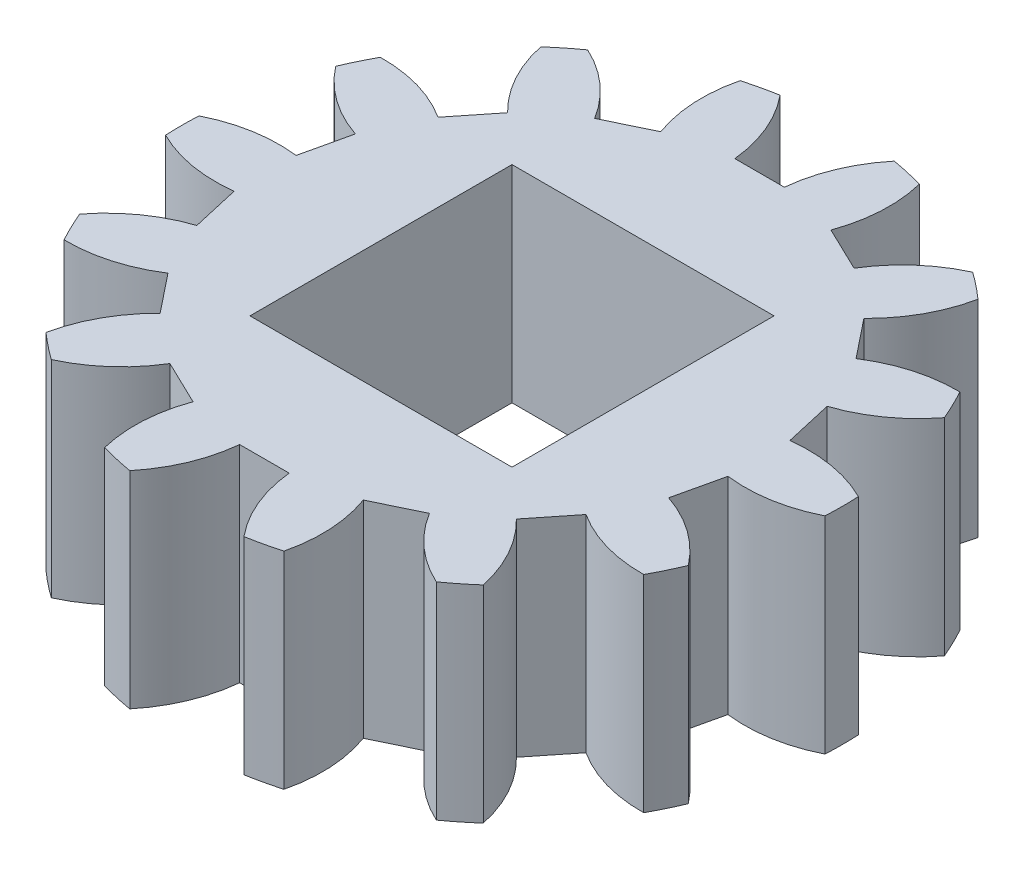
from build123d import *

# Parameters (mm, degrees)
SKETCH3_R           = 8
BOSS_EXTRUDE3_DEPTH = 5
CUT_EXTRUDE1_DEPTH  = 6
SKETCH5_W           = 6.35
SKETCH5_H           = 6.35
CUT_EXTRUDE2_DEPTH  = 6


with BuildPart() as part:
    # Sketch3 → Boss-Extrude3 (new body)
    with BuildSketch(Plane(origin=(0, 0, 0), x_dir=(1, 0, 0), z_dir=(0, 1, 0))):
        Circle(SKETCH3_R)
    extrude(amount=BOSS_EXTRUDE3_DEPTH)

    # Sketch4 → Cut-Extrude1 (cut, through all)
    with BuildSketch(Plane(origin=(0, 5, 0), x_dir=(1, 0, 0), z_dir=(0, 1, 0))):
        with BuildLine():
            Line((-0.6, 6), (0.6, 6))
            ThreePointArc((0.6, 6), (0.851894231, 6.997970737), (1.383186803, 7.879517388))
            ThreePointArc((1.383186803, 7.879517388), (0, 8), (-1.383186803, 7.879517388))
            ThreePointArc((-1.383186803, 7.879517388), (-0.851894231, 6.997970737), (-0.6, 6))
        make_face()
        with BuildLine():
            Line((2.062721114, 5.666143451), (3.143883755, 5.145482964))
            ThreePointArc((3.143883755, 5.145482964), (3.80383589, 5.935330718), (4.665002715, 6.499057599))
            ThreePointArc((4.665002715, 6.499057599), (3.471069913, 7.207750943), (2.172586219, 7.699342123))
            ThreePointArc((2.172586219, 7.699342123), (2.268775529, 6.674576827), (2.062721114, 5.666143451))
        make_face()
        with BuildLine():
            Line((4.316895014, 4.210037701), (5.065082776, 3.271839922))
            ThreePointArc((5.065082776, 3.271839922), (6.002381201, 3.697125659), (7.022857626, 3.831379746))
            ThreePointArc((7.022857626, 3.831379746), (6.25465186, 4.987918415), (5.298051895, 5.994217724))
            ThreePointArc((5.298051895, 5.994217724), (4.94008647, 5.029201118), (4.316895014, 4.210037701))
        make_face()
        with BuildLine():
            Line((5.716054913, 1.920082351), (5.983080033, 0.750168856))
            ThreePointArc((5.983080033, 0.750168856), (7.0120813, 0.72665952), (7.989749455, 0.404850146))
            ThreePointArc((7.989749455, 0.404850146), (7.799423297, 1.780167472), (7.374173417, 3.10186499))
            ThreePointArc((7.374173417, 3.10186499), (6.6329527, 2.387730448), (5.716054913, 1.920082351))
        make_face()
        with BuildLine():
            Line((5.983080033, -0.750168856), (5.716054913, -1.920082351))
            ThreePointArc((5.716054913, -1.920082351), (6.6329527, -2.387730448), (7.374173417, -3.10186499))
            ThreePointArc((7.374173417, -3.10186499), (7.799423297, -1.780167472), (7.989749455, -0.404850146))
            ThreePointArc((7.989749455, -0.404850146), (7.0120813, -0.72665952), (5.983080033, -0.750168856))
        make_face()
        with BuildLine():
            Line((5.065082776, -3.271839922), (4.316895014, -4.210037701))
            ThreePointArc((4.316895014, -4.210037701), (4.94008647, -5.029201118), (5.298051895, -5.994217724))
            ThreePointArc((5.298051895, -5.994217724), (6.25465186, -4.987918415), (7.022857626, -3.831379746))
            ThreePointArc((7.022857626, -3.831379746), (6.002381201, -3.697125659), (5.065082776, -3.271839922))
        make_face()
        with BuildLine():
            Line((3.143883755, -5.145482964), (2.062721114, -5.666143451))
            ThreePointArc((2.062721114, -5.666143451), (2.268775529, -6.674576827), (2.172586219, -7.699342123))
            ThreePointArc((2.172586219, -7.699342123), (3.471069913, -7.207750943), (4.665002715, -6.499057599))
            ThreePointArc((4.665002715, -6.499057599), (3.80383589, -5.935330718), (3.143883755, -5.145482964))
        make_face()
        with BuildLine():
            Line((0.6, -6), (-0.6, -6))
            ThreePointArc((-0.6, -6), (-0.851894231, -6.997970737), (-1.383186803, -7.879517388))
            ThreePointArc((-1.383186803, -7.879517388), (0, -8), (1.383186803, -7.879517388))
            ThreePointArc((1.383186803, -7.879517388), (0.851894231, -6.997970737), (0.6, -6))
        make_face()
        with BuildLine():
            Line((-2.062721114, -5.666143451), (-3.143883755, -5.145482964))
            ThreePointArc((-3.143883755, -5.145482964), (-3.80383589, -5.935330718), (-4.665002715, -6.499057599))
            ThreePointArc((-4.665002715, -6.499057599), (-3.471069913, -7.207750943), (-2.172586219, -7.699342123))
            ThreePointArc((-2.172586219, -7.699342123), (-2.268775529, -6.674576827), (-2.062721114, -5.666143451))
        make_face()
        with BuildLine():
            Line((-4.316895014, -4.210037701), (-5.065082776, -3.271839922))
            ThreePointArc((-5.065082776, -3.271839922), (-6.002381201, -3.697125659), (-7.022857626, -3.831379746))
            ThreePointArc((-7.022857626, -3.831379746), (-6.25465186, -4.987918415), (-5.298051895, -5.994217724))
            ThreePointArc((-5.298051895, -5.994217724), (-4.94008647, -5.029201118), (-4.316895014, -4.210037701))
        make_face()
        with BuildLine():
            Line((-5.716054913, -1.920082351), (-5.983080033, -0.750168856))
            ThreePointArc((-5.983080033, -0.750168856), (-7.0120813, -0.72665952), (-7.989749455, -0.404850146))
            ThreePointArc((-7.989749455, -0.404850146), (-7.799423297, -1.780167472), (-7.374173417, -3.10186499))
            ThreePointArc((-7.374173417, -3.10186499), (-6.6329527, -2.387730448), (-5.716054913, -1.920082351))
        make_face()
        with BuildLine():
            Line((-5.983080033, 0.750168856), (-5.716054913, 1.920082351))
            ThreePointArc((-5.716054913, 1.920082351), (-6.6329527, 2.387730448), (-7.374173417, 3.10186499))
            ThreePointArc((-7.374173417, 3.10186499), (-7.799423297, 1.780167472), (-7.989749455, 0.404850146))
            ThreePointArc((-7.989749455, 0.404850146), (-7.0120813, 0.72665952), (-5.983080033, 0.750168856))
        make_face()
        with BuildLine():
            Line((-5.065082776, 3.271839922), (-4.316895014, 4.210037701))
            ThreePointArc((-4.316895014, 4.210037701), (-4.94008647, 5.029201118), (-5.298051895, 5.994217724))
            ThreePointArc((-5.298051895, 5.994217724), (-6.25465186, 4.987918415), (-7.022857626, 3.831379746))
            ThreePointArc((-7.022857626, 3.831379746), (-6.002381201, 3.697125659), (-5.065082776, 3.271839922))
        make_face()
        with BuildLine():
            Line((-3.143883755, 5.145482964), (-2.062721114, 5.666143451))
            ThreePointArc((-2.062721114, 5.666143451), (-2.268775529, 6.674576827), (-2.172586219, 7.699342123))
            ThreePointArc((-2.172586219, 7.699342123), (-3.471069913, 7.207750943), (-4.665002715, 6.499057599))
            ThreePointArc((-4.665002715, 6.499057599), (-3.80383589, 5.935330718), (-3.143883755, 5.145482964))
        make_face()
    extrude(amount=-CUT_EXTRUDE1_DEPTH, mode=Mode.SUBTRACT)

    # Sketch5 → Cut-Extrude2 (cut, through all)
    with BuildSketch(Plane(origin=(0, 5, 0), x_dir=(1, 0, 0), z_dir=(0, 1, 0))):
        Rectangle(SKETCH5_W, SKETCH5_H)
    extrude(amount=-CUT_EXTRUDE2_DEPTH, mode=Mode.SUBTRACT)


solid = part.part
